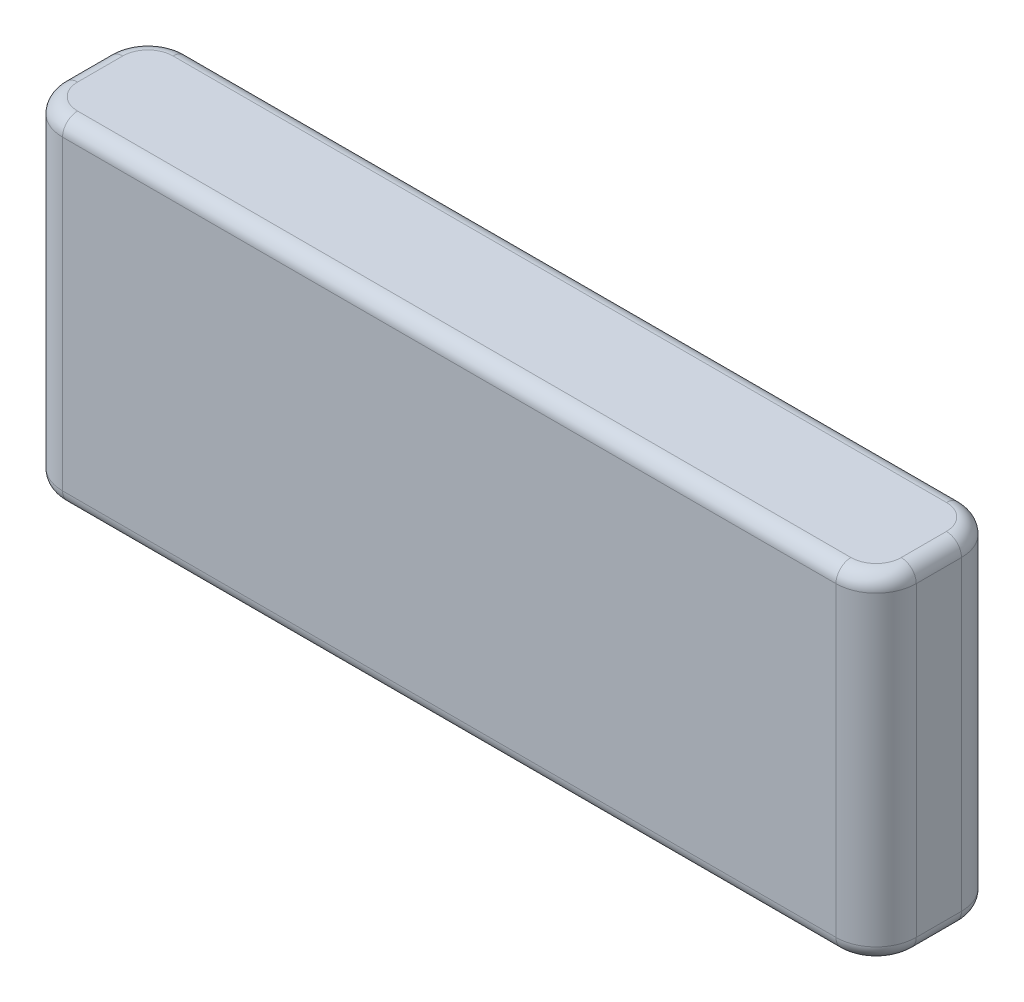
from build123d import *

# Parameters (mm, degrees)
SKETCH1_W           = 170
SKETCH1_H           = 25
BOSS_EXTRUDE1_DEPTH = 33.5
FILLET1_R           = 8
FILLET2_R           = 3


with BuildPart() as part:
    # Sketch1 → Boss-Extrude1 (new body, symmetric)
    with BuildSketch(Plane(origin=(0, 0, 0), x_dir=(1, 0, 0), z_dir=(0, 1, 0))):
        Rectangle(SKETCH1_W, SKETCH1_H)
    extrude(amount=BOSS_EXTRUDE1_DEPTH, both=True)

    # Fillet1
    fillet1_edges = [part.edges().sort_by_distance(p)[0] for p in [
        (-85, 0, -12.5),
        (85, 0, -12.5),
        (85, 0, 12.5),
        (-85, 0, 12.5),
    ]]
    fillet(fillet1_edges, radius=FILLET1_R)

    # Fillet2
    fillet2_edges = [part.edges().sort_by_distance(p)[0] for p in [
        (0, -33.5, 12.5),
        (0, 33.5, 12.5),
        (-85, -33.5, 0),
        (0, -33.5, -12.5),
        (85, -33.5, 0),
        (82.656854249, -33.5, 10.156854249),
        (82.656854249, -33.5, -10.156854249),
        (-82.656854249, -33.5, -10.156854249),
        (-82.656854249, -33.5, 10.156854249),
        (-85, 33.5, 0),
        (85, 33.5, 0),
        (0, 33.5, -12.5),
        (82.656854249, 33.5, 10.156854249),
        (82.656854249, 33.5, -10.156854249),
        (-82.656854249, 33.5, -10.156854249),
        (-82.656854249, 33.5, 10.156854249),
    ]]
    fillet(fillet2_edges, radius=FILLET2_R)


solid = part.part
